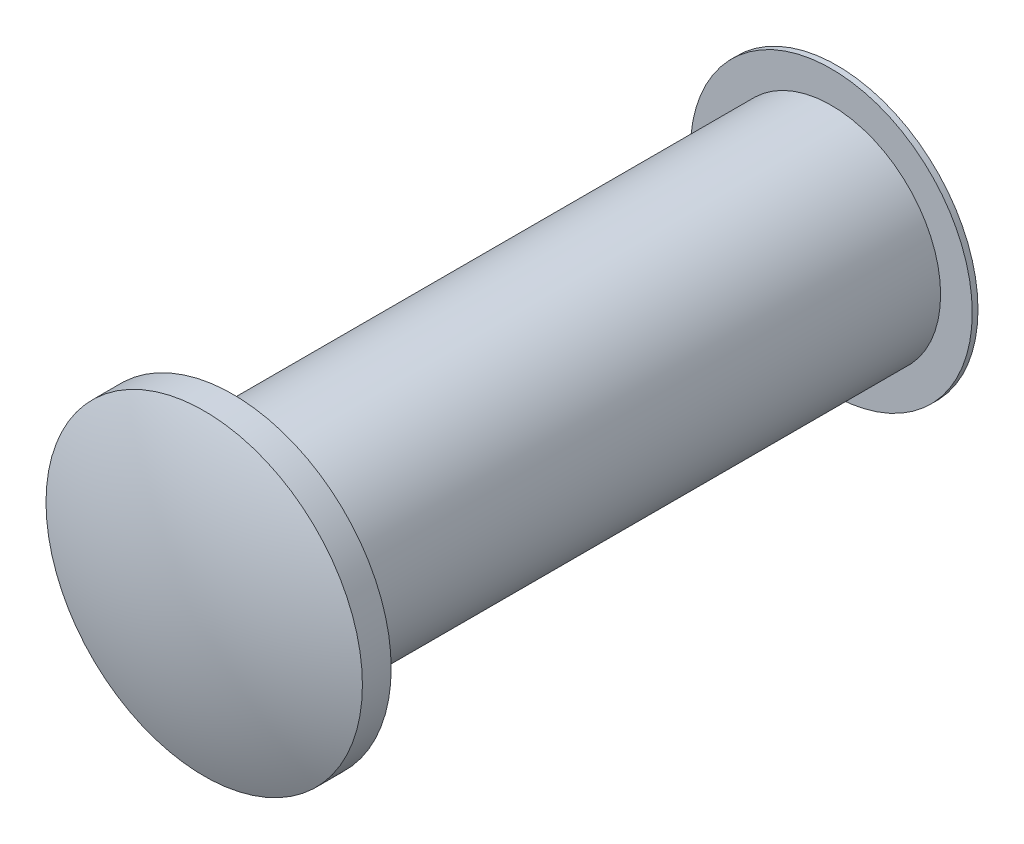
from build123d import *

# Parameters (mm, degrees)
SKETCH1_R           = 0.9652
BOSS_EXTRUDE1_DEPTH = 5.2832
SKETCH2_R           = 1.397
BOSS_EXTRUDE2_DEPTH = 0.254
DOME1_FACE_RADIUS   = 1.397
DOME1_HEIGHT        = 0.2794
SKETCH3_R           = 1.2446
BOSS_EXTRUDE3_DEPTH = 0.0508
SKETCH4_R           = 0.592078561
CUT_EXTRUDE1_DEPTH  = 0.508


with BuildPart() as part:
    # Sketch1 → Boss-Extrude1 (new body)
    with BuildSketch(Plane.XY):
        Circle(SKETCH1_R)
    extrude(amount=BOSS_EXTRUDE1_DEPTH)

    # Sketch2 → Boss-Extrude2 (add)
    with BuildSketch(Plane.XY.offset(5.2832)):
        Circle(SKETCH2_R)
    extrude(amount=BOSS_EXTRUDE2_DEPTH)

    # Dome1: a dome of height H over a round flat face of radius A is a cap of a sphere of radius (A * A + H * H) / (2 * H)
    dome1_r = (DOME1_FACE_RADIUS * DOME1_FACE_RADIUS + DOME1_HEIGHT * DOME1_HEIGHT) / (2 * DOME1_HEIGHT)
    dome1_base = Plane((0, 0, 5.5372), z_dir=(0, 0, 1))
    with Locations(dome1_base.offset(DOME1_HEIGHT - dome1_r)):
        dome1_ball = Sphere(dome1_r, mode=Mode.PRIVATE)
    add(split(dome1_ball, bisect_by=dome1_base, keep=Keep.TOP, mode=Mode.PRIVATE))

    # Sketch3 → Boss-Extrude3 (add)
    with BuildSketch(Plane(origin=(0, 0, 0), x_dir=(-1, 0, 0), z_dir=(0, 0, -1))):
        Circle(SKETCH3_R)
    extrude(amount=BOSS_EXTRUDE3_DEPTH)

    # Sketch4 → Cut-Extrude1 (cut)
    with BuildSketch(Plane(origin=(0, 0, -0.0508), x_dir=(-1, 0, 0), z_dir=(0, 0, -1))):
        Circle(SKETCH4_R)
    extrude(amount=-CUT_EXTRUDE1_DEPTH, mode=Mode.SUBTRACT)


solid = part.part
